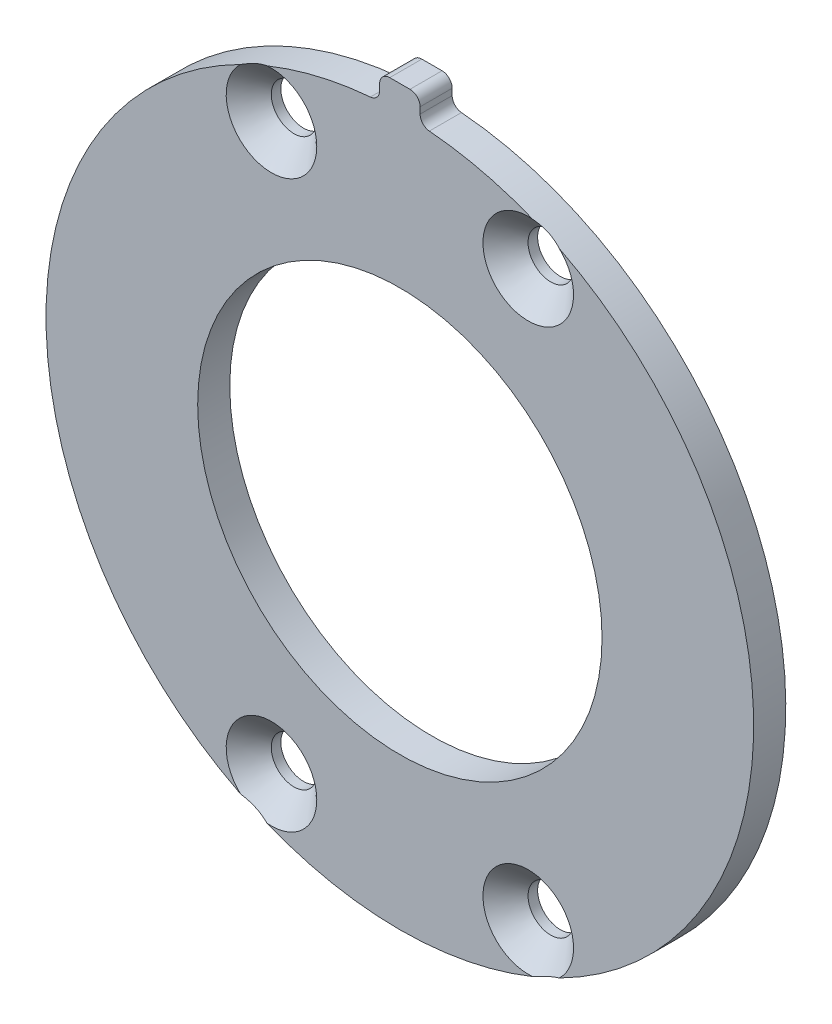
from build123d import *

# Parameters (mm, degrees)
SKETCH2_R                    = 35
SKETCH2_R_2                  = 20
BOSS_EXTRUDE1_DEPTH          = 3.175
CSK_FOR_M4_SFHCS1_AT_2_COUNT = 2
CSK_FOR_M4_SFHCS1_AT_2_PITCH = 25.4
CSK_FOR_M4_SFHCS1_AT_3_COUNT = 2
CSK_FOR_M4_SFHCS1_AT_3_PITCH = 61.454142663
CSK_FOR_M4_SFHCS1_AT_4_COUNT = 2
CSK_FOR_M4_SFHCS1_AT_4_PITCH = 55.959375
SKETCH5_W                    = 4
SKETCH5_H                    = 5
BOSS_EXTRUDE2_DEPTH          = 3.175
FILLET1_R                    = 1


with BuildPart() as part:
    # Sketch2 → Boss-Extrude1 (new body)
    with BuildSketch(Plane.XY):
        Circle(SKETCH2_R)
        Circle(SKETCH2_R_2, mode=Mode.SUBTRACT)
    extrude(amount=BOSS_EXTRUDE1_DEPTH)

    # Sketch4 → CSK for M4 SFHCS1 (revolve, cut)
    with BuildSketch(Plane(origin=(-12.7, 27.9796875, 3.175), x_dir=(0, -1, 0), z_dir=(1, 0, 0))):
        Polygon((0, 0), (0, 3.175), (2.25, 3.175), (2.25, 2.23), (4.48, 0), align=None)
    csk_for_m4_sfhcs1 = revolve(axis=Axis((-12.7, 27.9796875, 9.525), (0, 0, -1)), mode=Mode.SUBTRACT)

    # CSK for M4 SFHCS1 at 2: CSK for M4 SFHCS1 ×2
    with Locations(*[(i * CSK_FOR_M4_SFHCS1_AT_2_PITCH, 0, 0) for i in range(1, CSK_FOR_M4_SFHCS1_AT_2_COUNT)]):
        add(csk_for_m4_sfhcs1, mode=Mode.SUBTRACT)

    # CSK for M4 SFHCS1 at 3: CSK for M4 SFHCS1 ×2
    with Locations(*[Vector(0.413316318, -0.910587514, 0) * (i * CSK_FOR_M4_SFHCS1_AT_3_PITCH) for i in range(1, CSK_FOR_M4_SFHCS1_AT_3_COUNT)]):
        add(csk_for_m4_sfhcs1, mode=Mode.SUBTRACT)

    # CSK for M4 SFHCS1 at 4: CSK for M4 SFHCS1 ×2
    with Locations(*[(0, -i * CSK_FOR_M4_SFHCS1_AT_4_PITCH, 0) for i in range(1, CSK_FOR_M4_SFHCS1_AT_4_COUNT)]):
        add(csk_for_m4_sfhcs1, mode=Mode.SUBTRACT)

    # Sketch5 → Boss-Extrude2 (add)
    with BuildSketch(Plane(origin=(0, 0, 0), x_dir=(-1, 0, 0), z_dir=(0, 0, -1))):
        with Locations((0, 35)):
            Rectangle(SKETCH5_W, SKETCH5_H)
    extrude(amount=-BOSS_EXTRUDE2_DEPTH)

    # Fillet1
    fillet1_edges = [part.edges().sort_by_distance(p)[0] for p in [
        (-2, 37.5, 1.5875),
        (-2, 34.942810419, 1.5875),
        (2, 37.5, 1.5875),
        (2, 34.942810419, 1.5875),
    ]]
    fillet(fillet1_edges, radius=FILLET1_R)


solid = part.part
